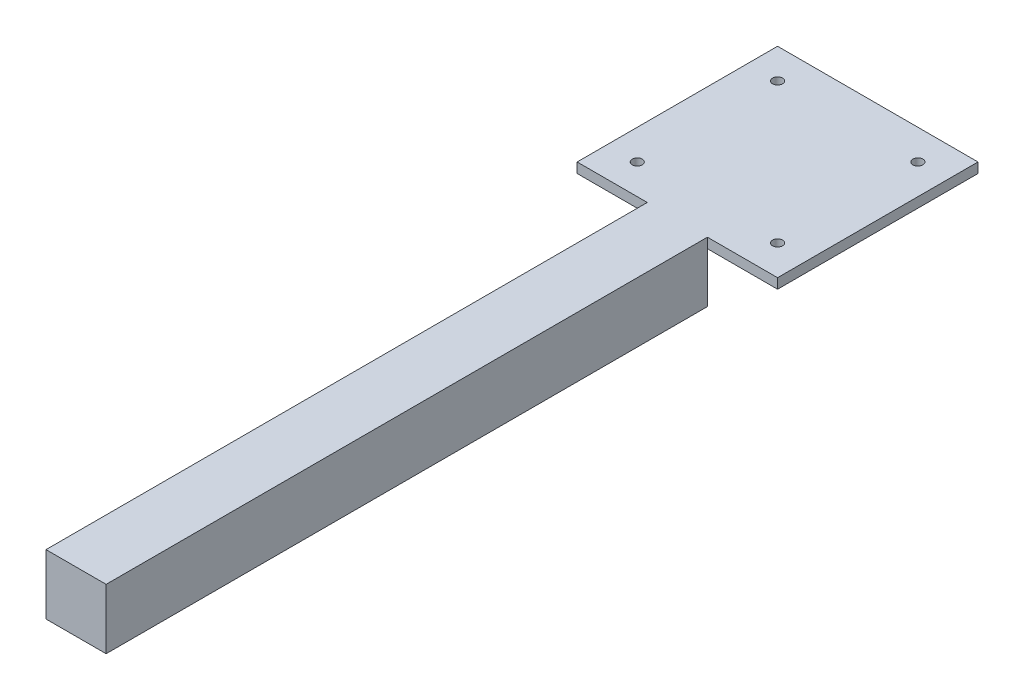
from build123d import *

# Parameters (mm, degrees)
SKETCH1_W           = 30
SKETCH1_H           = 30
BOSS_EXTRUDE1_DEPTH = 300
SKETCH2_W           = 100
SKETCH2_H           = 100
BOSS_EXTRUDE2_DEPTH = 5
CUT_EXTRUDE1_REACH  = 32
SKETCH3_R           = 2.5


with BuildPart() as part:
    # Sketch1 → Boss-Extrude1 (new body)
    with BuildSketch(Plane.XY):
        Rectangle(SKETCH1_W, SKETCH1_H)
    extrude(amount=BOSS_EXTRUDE1_DEPTH)

    # Sketch2 → Boss-Extrude2 (add)
    with BuildSketch(Plane(origin=(0, 15, 0), x_dir=(1, 0, 0), z_dir=(0, 1, 0))):
        with Locations((0, 50)):
            Rectangle(SKETCH2_W, SKETCH2_H)
    extrude(amount=-BOSS_EXTRUDE2_DEPTH)

    # Sketch3 → Cut-Extrude1 (cut, up to next)
    with BuildSketch(Plane(origin=(0, 15, 0), x_dir=(1, 0, 0), z_dir=(0, 1, 0)), mode=Mode.PRIVATE) as cut_extrude1_sk1:
        with Locations((-35, 15)):
            Circle(SKETCH3_R)
    cut_extrude1_tool1 = extrude(cut_extrude1_sk1.sketch, amount=-CUT_EXTRUDE1_REACH, mode=Mode.PRIVATE) & part.part
    add(cut_extrude1_tool1.solids().sort_by_distance((-35, 15, -15))[0], mode=Mode.SUBTRACT)
    # Sketch3 → Cut-Extrude1 (cut, up to next)
    with BuildSketch(Plane(origin=(0, 15, 0), x_dir=(1, 0, 0), z_dir=(0, 1, 0)), mode=Mode.PRIVATE) as cut_extrude1_sk2:
        with Locations((35, 15)):
            Circle(SKETCH3_R)
    cut_extrude1_tool2 = extrude(cut_extrude1_sk2.sketch, amount=-CUT_EXTRUDE1_REACH, mode=Mode.PRIVATE) & part.part
    add(cut_extrude1_tool2.solids().sort_by_distance((35, 15, -15))[0], mode=Mode.SUBTRACT)
    # Sketch3 → Cut-Extrude1 (cut, up to next)
    with BuildSketch(Plane(origin=(0, 15, 0), x_dir=(1, 0, 0), z_dir=(0, 1, 0)), mode=Mode.PRIVATE) as cut_extrude1_sk3:
        with Locations((-35, 85)):
            Circle(SKETCH3_R)
    cut_extrude1_tool3 = extrude(cut_extrude1_sk3.sketch, amount=-CUT_EXTRUDE1_REACH, mode=Mode.PRIVATE) & part.part
    add(cut_extrude1_tool3.solids().sort_by_distance((-35, 15, -85))[0], mode=Mode.SUBTRACT)
    # Sketch3 → Cut-Extrude1 (cut, up to next)
    with BuildSketch(Plane(origin=(0, 15, 0), x_dir=(1, 0, 0), z_dir=(0, 1, 0)), mode=Mode.PRIVATE) as cut_extrude1_sk4:
        with Locations((35, 85)):
            Circle(SKETCH3_R)
    cut_extrude1_tool4 = extrude(cut_extrude1_sk4.sketch, amount=-CUT_EXTRUDE1_REACH, mode=Mode.PRIVATE) & part.part
    add(cut_extrude1_tool4.solids().sort_by_distance((35, 15, -85))[0], mode=Mode.SUBTRACT)


solid = part.part
